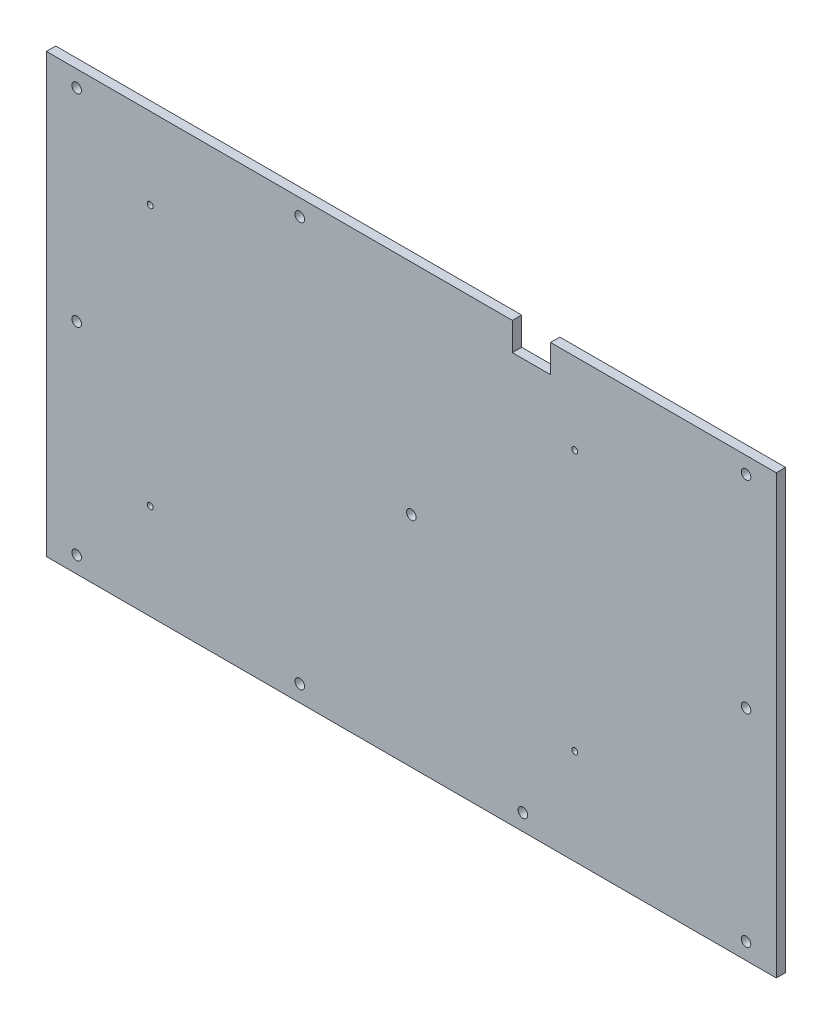
from build123d import *

# Parameters (mm, degrees)
BOSS_EXTRUDE1_DEPTH       = 3.175
F_4_CLEARANCE_HOLE1_D     = 3.2639
F_4_CLEARANCE_HOLE1_DEPTH = 56.388
F_4_CLEARANCE_HOLE1_TIP   = 0.980574487
F_4_40_TAPPED_HOLE1_D     = 2.032
F_4_40_TAPPED_HOLE1_DEPTH = 7.62
F_4_40_TAPPED_HOLE1_TIP   = 0.610474389


with BuildPart() as part:
    # Sketch1 → Boss-Extrude1 (new body)
    with BuildSketch(Plane.XY):
        Polygon((34.4424, 65.0875), (34.4424, 74.6125), (-124.46, 74.6125), (-124.46, -74.6125), (124.46, -74.6125), (124.46, 74.6125), (47.4726, 74.6125), (47.4726, 65.0875), align=None)
    extrude(amount=BOSS_EXTRUDE1_DEPTH)

    # #4 Clearance Hole1
    with Locations(Plane(origin=(0, 0, 0), x_dir=(-1, 0, 0), z_dir=(0, 0, -1))):
        with Locations((114.1476, -68.9864), (-114.1476, -68.9864), (-114.1476, 68.9864), (114.1476, 68.9864), (114.1476, 0), (-114.1476, 0), (38.0492, 68.9864), (-38.0492, 68.9864), (-38.0492, -68.9864), (38.0492, -68.9864), (0, 0)):
            Hole(F_4_CLEARANCE_HOLE1_D / 2, depth=F_4_CLEARANCE_HOLE1_DEPTH)
            with Locations((0, 0, -(F_4_CLEARANCE_HOLE1_DEPTH + F_4_CLEARANCE_HOLE1_TIP / 2))):  # 118° drill point
                Cone(0, F_4_CLEARANCE_HOLE1_D / 2, F_4_CLEARANCE_HOLE1_TIP, mode=Mode.SUBTRACT)

    # #4-40 Tapped Hole1
    with Locations(Plane(origin=(0, 0, 0), x_dir=(-1, 0, 0), z_dir=(0, 0, -1))):
        with Locations((-55.7276, -41.9735), (-55.7276, 46.9265), (89.0524, 46.9265), (89.0524, -41.9735)):
            Hole(F_4_40_TAPPED_HOLE1_D / 2, depth=F_4_40_TAPPED_HOLE1_DEPTH)
            with Locations((0, 0, -(F_4_40_TAPPED_HOLE1_DEPTH + F_4_40_TAPPED_HOLE1_TIP / 2))):  # 118° drill point
                Cone(0, F_4_40_TAPPED_HOLE1_D / 2, F_4_40_TAPPED_HOLE1_TIP, mode=Mode.SUBTRACT)


solid = part.part
